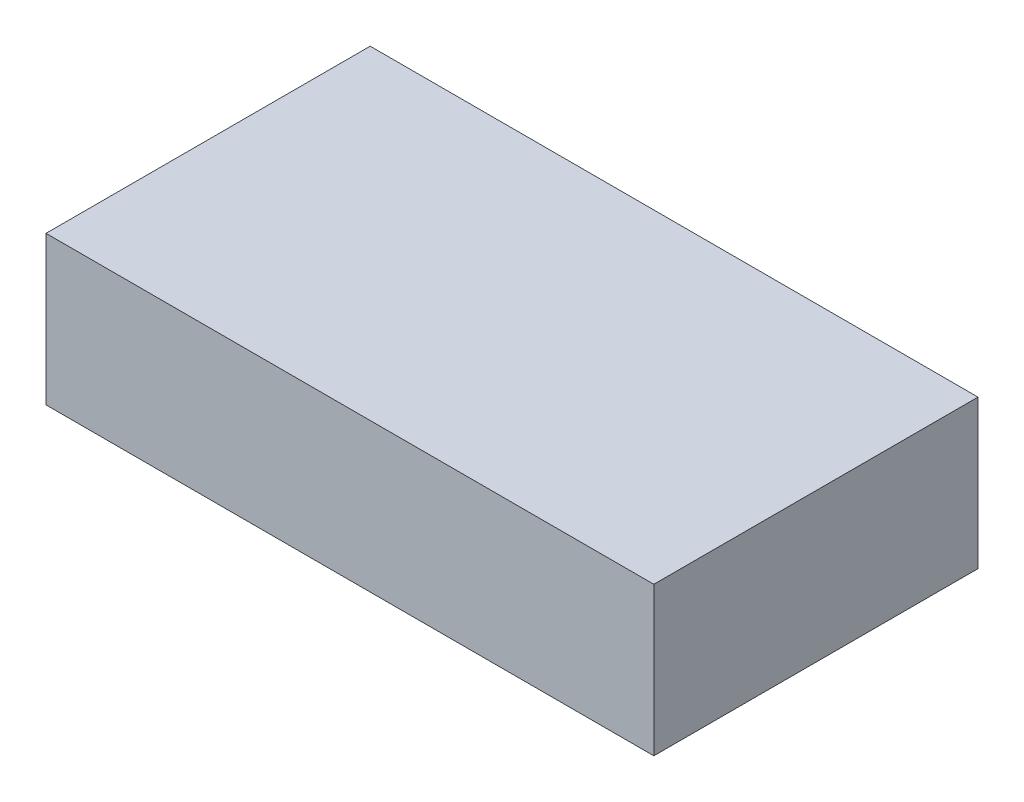
from build123d import *

# Parameters (mm, degrees)
SKETCH1_W           = 45
SKETCH1_H           = 24
BOSS_EXTRUDE1_DEPTH = 11


with BuildPart() as part:
    # Sketch1 → Boss-Extrude1 (new body)
    with BuildSketch(Plane(origin=(0, 0, 0), x_dir=(1, 0, 0), z_dir=(0, 1, 0))):
        Rectangle(SKETCH1_W, SKETCH1_H)
    extrude(amount=BOSS_EXTRUDE1_DEPTH)


solid = part.part
